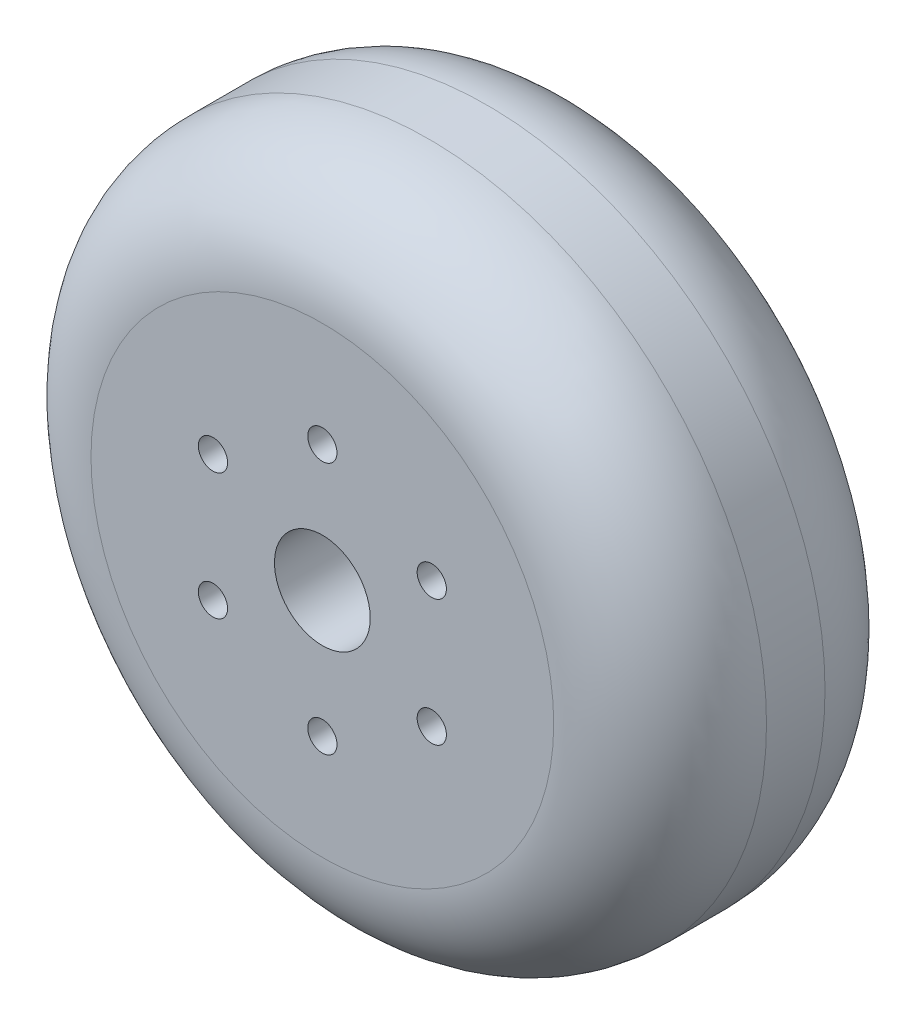
from build123d import *

# Parameters (mm, degrees)
SKETCH1_R            = 63.5
SKETCH1_R_2          = 9
BOSS_EXTRUDE1_DEPTH  = 51
FILLET1_R            = 20
M5_CLEARANCE_HOLE1_D = 5.5


with BuildPart() as part:
    # Sketch1 → Boss-Extrude1 (new body)
    with BuildSketch(Plane.XY):
        Circle(SKETCH1_R)
        Circle(SKETCH1_R_2, mode=Mode.SUBTRACT)
    extrude(amount=BOSS_EXTRUDE1_DEPTH)

    # Fillet1
    fillet1_edges = [part.edges().sort_by_distance(p)[0] for p in [
        (-63.5, 0, 0),
        (-63.5, 0, 51),
    ]]
    fillet(fillet1_edges, radius=FILLET1_R)

    # M5 Clearance Hole1 (through all)
    with Locations(Plane.XY.offset(51)):
        with Locations((0, 23.75), (20.56810334, 11.875), (20.56810334, -11.875), (0, -23.75), (-20.56810334, -11.875), (-20.56810334, 11.875)):
            Hole(M5_CLEARANCE_HOLE1_D / 2)


solid = part.part
